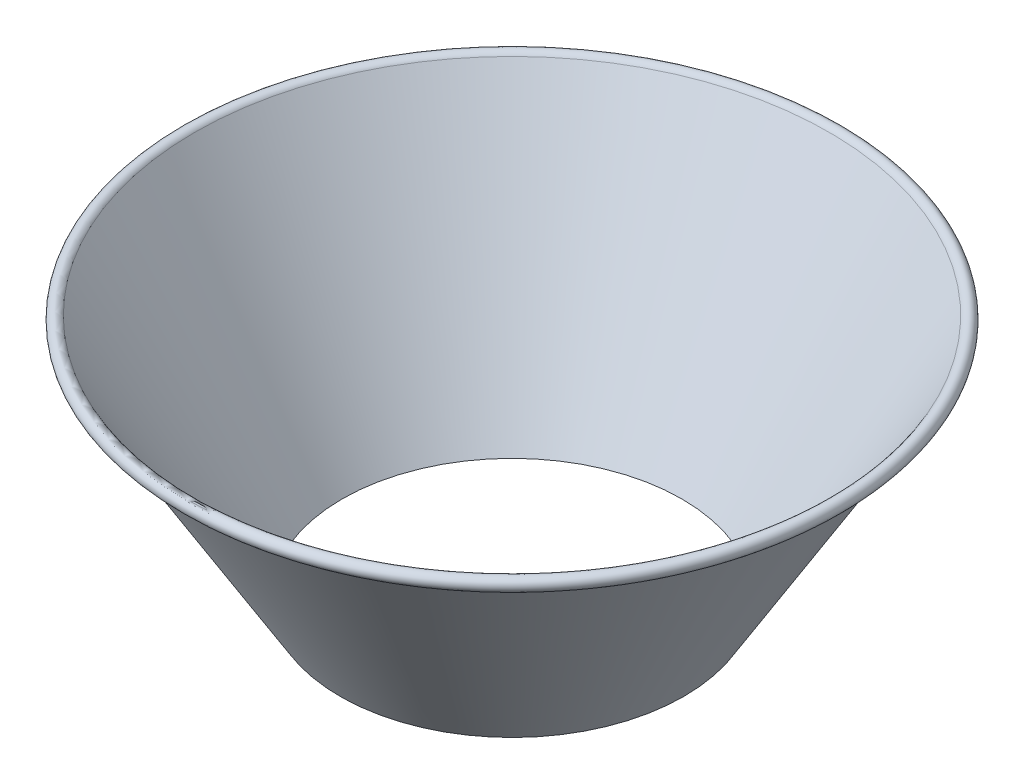
from build123d import *

# Parameters (mm, degrees)
FILLET1_R               = 2.54
SKETCH11_W              = 76.2
SKETCH11_H              = 114.3
CUT_EXTRUDE1_DEPTH      = 74.0250001
CUT_EXTRUDE1_DEPTH_BACK = 74.0250001


with BuildPart() as part:
    # Sketch3 → Revolve1 (revolve)
    with BuildSketch(Plane.XY):
        with BuildLine():
            Line((-71.5645, 73.279), (-71.5645, 73.66))
            ThreePointArc((-71.5645, 73.66), (-72.504664711, 75.269981447), (-70.640479738, 75.297627948))
            Line((-70.640479738, 75.297627948), (-70.13186321, 74.455577339))
            Line((-70.13186321, 74.455577339), (-13.6525, -19.05))
            Line((-13.6525, -19.05), (-12.065, -19.05))
            Line((-12.065, -19.05), (-12.1031, -18.669))
            Line((-12.1031, -18.669), (-13.437523381, -18.669))
            Line((-13.437523381, -18.669), (-70.31435494, 75.494614282))
            ThreePointArc((-70.31435494, 75.494614282), (-72.836487551, 75.457210193), (-71.5645, 73.279))
        make_face()
    revolve(axis=Axis((0, 76.2, 0), (0, -1, 0)))

    # Sketch4 → Revolve2 (revolve)
    with BuildSketch(Plane.XY):
        Polygon((-5.967099739, -76.2), (-11.682099739, -19.05), (-11.752974875, -18.341248634), (-13.635492197, -18.341248634), (-13.437523381, -18.669), (-12.1031, -18.669), (-12.065, -19.05), (-6.35, -76.2), align=None)
    revolve(axis=Axis((0, 76.2, 0), (0, -1, 0)))

    # Fillet1
    fillet1_edges = [part.edges().sort_by_distance(p)[0] for p in [
        (13.6525, -19.05, 0),
    ]]
    fillet(fillet1_edges, radius=FILLET1_R)

    # Sketch11 → Cut-Extrude1 (cut, two sides)
    with BuildSketch(Plane.XY) as cut_extrude1_sk:
        with Locations((0.012345185, -35.704997655)):
            Rectangle(SKETCH11_W, SKETCH11_H)
    extrude(amount=CUT_EXTRUDE1_DEPTH, mode=Mode.SUBTRACT)
    extrude(cut_extrude1_sk.sketch, amount=-CUT_EXTRUDE1_DEPTH_BACK, mode=Mode.SUBTRACT)


solid = part.part
